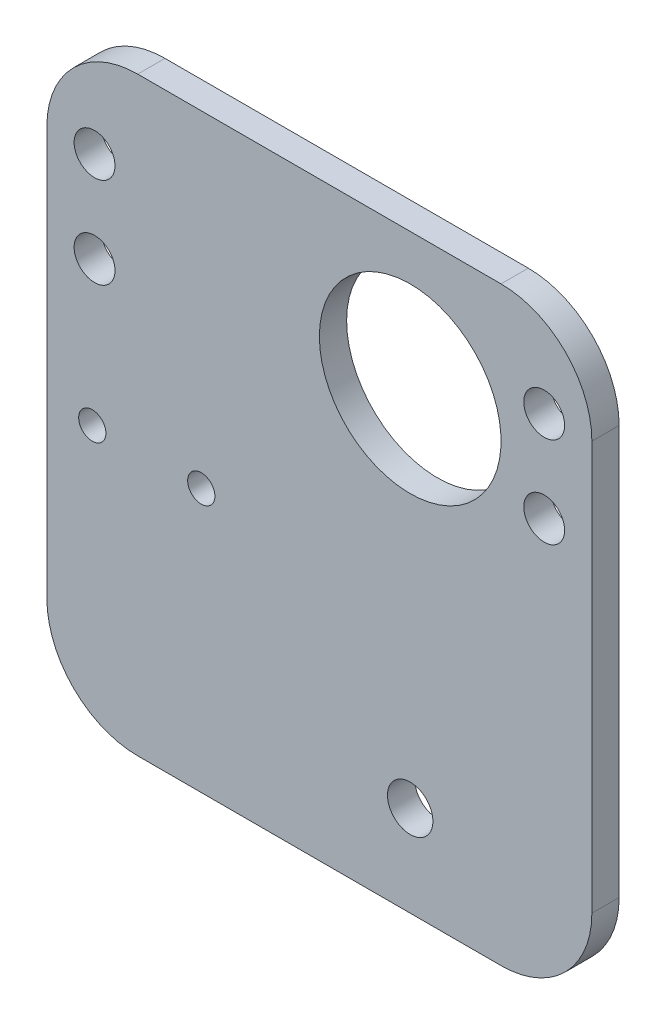
from build123d import *

# Parameters (mm, degrees)
SKETCH_3_R               = 3
EXTRUDE_6_DEPTH          = 0.001
EXTRUDE_6_2_DEPTH        = 0.001
EXTRUDE_6_3_DEPTH        = 0.001
EXTRUDE_6_4_DEPTH        = 0.001
SKETCH_11_R              = 2.25
CUT_EXTRUDE_2_DEPTH      = 1
CUT_EXTRUDE_2_DEPTH_BACK = 1.001
EXTRUDE_7_DEPTH          = 3
SKETCH_14_R              = 2.25
SKETCH_14_R_2            = 10
CUT_EXTRUDE_3_DEPTH      = 3
SKETCH_15_R              = 10
SKETCH_15_R_2            = 2.5
CUT_EXTRUDE_4_DEPTH      = 3
SKETCH_16_R              = 1.5
CUT_EXTRUDE_5_DEPTH      = 10
SKETCH_17_R              = 9.5
SKETCH_17_R_2            = 7.5
EXTRUDE_8_DEPTH          = 4.9
FILLET_1_R               = 10


with BuildPart() as part:
    # 草图3 → 凸台-拉伸6 (new body)
    with BuildSketch(Plane.XY):
        with Locations((60.266478541, 16.532501821)):
            Circle(SKETCH_3_R)
    extrude(amount=EXTRUDE_6_DEPTH)


with BuildPart() as body_2:
    # 草图3 → Extrude 6 2 (new body)
    with BuildSketch(Plane.XY):
        with Locations((60.266478541, 6.532501821)):
            Circle(SKETCH_3_R)
    extrude(amount=EXTRUDE_6_2_DEPTH)


with BuildPart() as body_3:
    # 草图3 → Extrude 6 3 (new body)
    with BuildSketch(Plane.XY):
        with Locations((10.766478541, 6.532501821)):
            Circle(SKETCH_3_R)
    extrude(amount=EXTRUDE_6_3_DEPTH)


with BuildPart() as body_4:
    # 草图3 → Extrude 6 4 (new body)
    with BuildSketch(Plane.XY):
        with Locations((10.766478541, 16.532501821)):
            Circle(SKETCH_3_R)
    extrude(amount=EXTRUDE_6_4_DEPTH)


with BuildPart() as cut_extrude_2_tool:
    # 草图11 → 切除-拉伸2 (new body, two sides)
    with BuildSketch(Plane.XY.offset(0.001)) as cut_extrude_2_sk:
        with Locations((10.766478541, 16.532501821)):
            Circle(SKETCH_11_R)
        with Locations((10.766478541, 6.532501821)):
            Circle(SKETCH_11_R)
        with Locations((60.266478541, 16.532501821)):
            Circle(SKETCH_11_R)
        with Locations((60.266478541, 6.532501821)):
            Circle(SKETCH_11_R)
    extrude(amount=CUT_EXTRUDE_2_DEPTH)
    extrude(cut_extrude_2_sk.sketch, amount=-CUT_EXTRUDE_2_DEPTH_BACK)


with BuildPart() as part_1:
    add(part.part)

    # 切除-拉伸2: cut by cut_extrude_2_tool
    add(cut_extrude_2_tool.part, mode=Mode.SUBTRACT)



with BuildPart() as body_2_1:
    add(body_2.part)

    # 切除-拉伸2: cut by cut_extrude_2_tool
    add(cut_extrude_2_tool.part, mode=Mode.SUBTRACT)


with BuildPart() as body_3_1:
    add(body_3.part)

    # 切除-拉伸2: cut by cut_extrude_2_tool
    add(cut_extrude_2_tool.part, mode=Mode.SUBTRACT)


with BuildPart() as body_4_1:
    add(body_4.part)

    # 切除-拉伸2: cut by cut_extrude_2_tool
    add(cut_extrude_2_tool.part, mode=Mode.SUBTRACT)


with BuildPart() as part_2:
    add(part_1.part)

    add(body_2_1.part)  # 凸台-拉伸7 merges body 2

    add(body_3_1.part)  # 凸台-拉伸7 merges body 3

    add(body_4_1.part)  # 凸台-拉伸7 merges body 4
    # 草图12 → 凸台-拉伸7 (add)
    with BuildSketch(Plane.XY.offset(0.001)):
        Polygon((5.516478541, 26.532501821), (65.516478541, 26.532501821), (65.516478541, -38.467498179), (5.516478541, -38.467498179), (5.516478541, 1.532501821), align=None)
    extrude(amount=EXTRUDE_7_DEPTH)

    # 草图14 → 切除-拉伸3 (cut)
    with BuildSketch(Plane(origin=(0, 0, 0.001), x_dir=(-1, 0, 0), z_dir=(0, 0, -1))):
        with Locations((-60.266478541, 6.532501821)):
            Circle(SKETCH_14_R)
        with Locations((-60.266478541, 16.532501821)):
            Circle(SKETCH_14_R)
        with Locations((-10.766478541, 6.532501821)):
            Circle(SKETCH_14_R)
        with Locations((-10.766478541, 16.532501821)):
            Circle(SKETCH_14_R)
        with Locations((-45.516478541, 11.532501821)):
            Circle(SKETCH_14_R_2)
    extrude(amount=-CUT_EXTRUDE_3_DEPTH, mode=Mode.SUBTRACT)

    # 草图15 → 切除-拉伸4 (cut)
    with BuildSketch(Plane(origin=(0, 0, 0.001), x_dir=(-1, 0, 0), z_dir=(0, 0, -1))):
        with Locations((-45.516478541, 11.532501821)):
            Circle(SKETCH_15_R)
        with Locations((-45.516478541, -28.467498179)):
            Circle(SKETCH_15_R_2)
    extrude(amount=-CUT_EXTRUDE_4_DEPTH, mode=Mode.SUBTRACT)

    # 草图16 → 切除-拉伸5 (cut)
    with BuildSketch(Plane.XY.offset(3.001)):
        with Locations((10.516478541, -9.467498179)):
            Circle(SKETCH_16_R)
        with Locations((22.516478541, -9.467498179)):
            Circle(SKETCH_16_R)
    extrude(amount=-CUT_EXTRUDE_5_DEPTH, mode=Mode.SUBTRACT)

    # 草图17 → 凸台-拉伸8 (add)
    with BuildSketch(Plane.XY.offset(3.001)):
        with Locations((45.516478541, -28.467498179)):
            Circle(SKETCH_17_R)
        with Locations((45.516478541, -28.467498179)):
            Circle(SKETCH_17_R_2, mode=Mode.SUBTRACT)
    extrude(amount=-EXTRUDE_8_DEPTH)

    # 圆角1
    fillet_1_edges = [part_2.edges().sort_by_distance(p)[0] for p in [
        (5.516478541, 26.532501821, 1.501),
        (5.516478541, -38.467498179, 1.501),
        (65.516478541, -38.467498179, 1.501),
        (65.516478541, 26.532501821, 1.501),
    ]]
    fillet(fillet_1_edges, radius=FILLET_1_R)


solid = part_2.part
